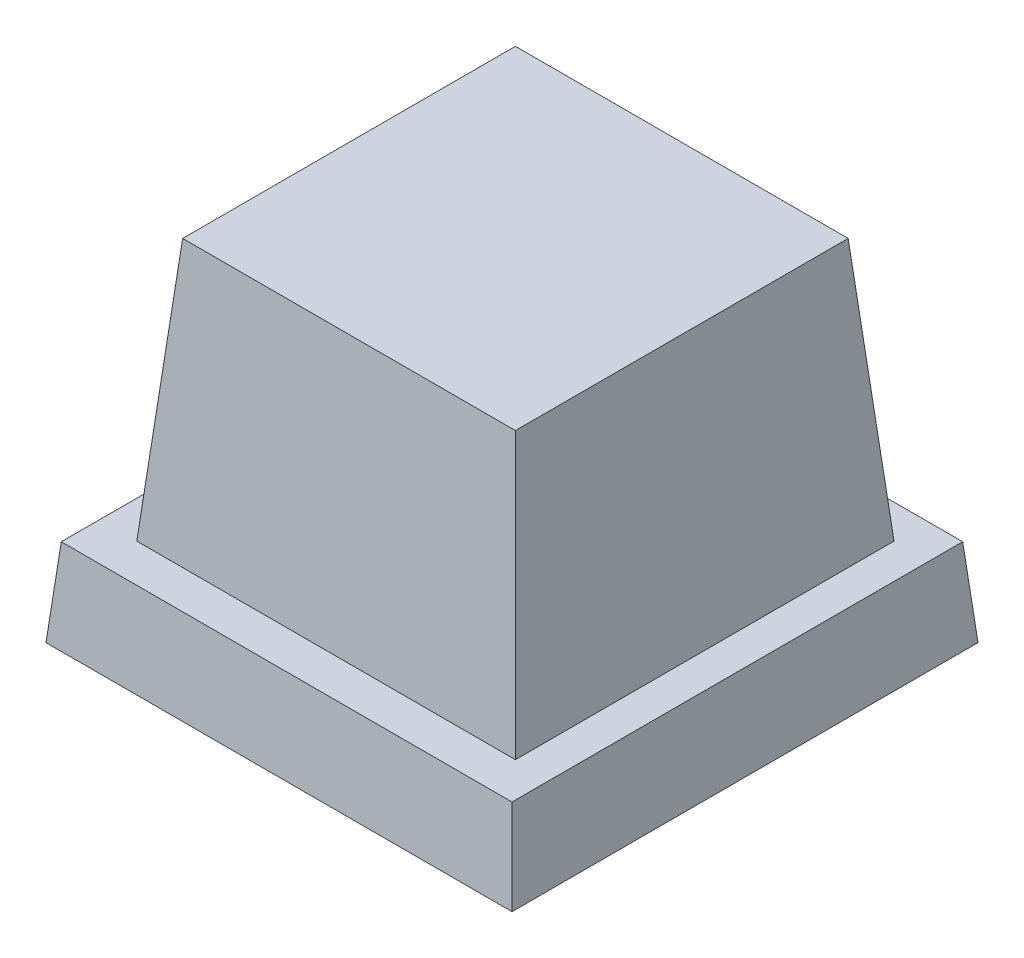
from build123d import *

# Parameters (mm, degrees)
SKETCH1_W           = 32
SKETCH1_H           = 32
BOSS_EXTRUDE1_DEPTH = 6
BOSS_EXTRUDE1_TAPER = 5
SKETCH2_W           = 26
SKETCH2_H           = 26
BOSS_EXTRUDE2_DEPTH = 18
BOSS_EXTRUDE2_TAPER = 5
SHELL1_T            = -0.8


with BuildPart() as part:
    # Sketch1 → Boss-Extrude1 (new body)
    with BuildSketch(Plane(origin=(0, 0, 0), x_dir=(1, 0, 0), z_dir=(0, 1, 0))):
        with Locations((-16, 16)):
            Rectangle(SKETCH1_W, SKETCH1_H)
    extrude(amount=BOSS_EXTRUDE1_DEPTH, taper=BOSS_EXTRUDE1_TAPER)

    # Sketch2 → Boss-Extrude2 (add)
    with BuildSketch(Plane(origin=(0, 6, 0), x_dir=(1, 0, 0), z_dir=(0, 1, 0))):
        with Locations((-15.92307672, 16.156742102)):
            Rectangle(SKETCH2_W, SKETCH2_H)
    extrude(amount=BOSS_EXTRUDE2_DEPTH, taper=BOSS_EXTRUDE2_TAPER)

    # Shell1
    shell1_openings = [part.faces().sort_by_distance(p)[0] for p in [
        (-16, 0, -16),
    ]]
    offset(amount=SHELL1_T, openings=shell1_openings, kind=Kind.INTERSECTION)


solid = part.part
